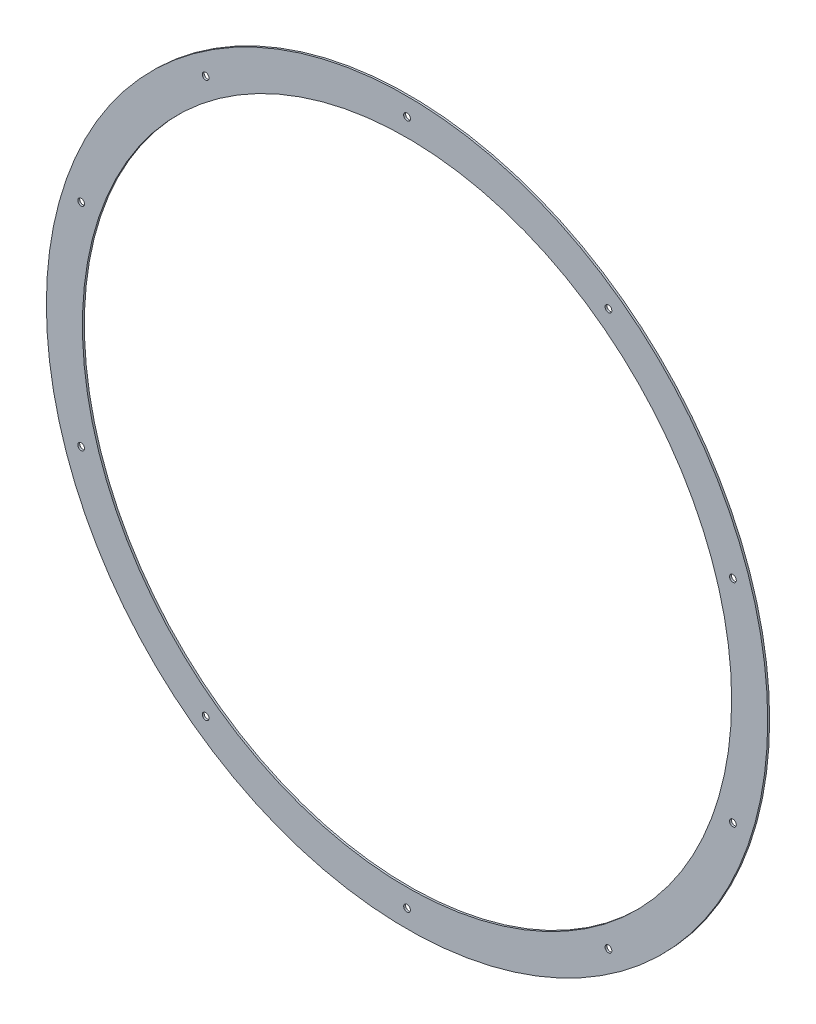
from build123d import *

# Parameters (mm, degrees)
SKETCH1_R          = 381
SKETCH1_R_2        = 342.9
EXTRUDE1_DEPTH     = 2.032
SKETCH2_R          = 3.556
CUT_EXTRUDE1_DEPTH = 2.032
CIRPATTERN1_COUNT  = 10


with BuildPart() as part:
    # Sketch1 → Extrude1 (new body)
    with BuildSketch(Plane.XY):
        Circle(SKETCH1_R)
        Circle(SKETCH1_R_2, mode=Mode.SUBTRACT)
    extrude(amount=EXTRUDE1_DEPTH)

    # Sketch2 → Cut-Extrude1 (cut)
    with BuildSketch(Plane.XY.offset(2.032)):
        with Locations((0, -361.95)):
            Circle(SKETCH2_R)
    cut_extrude1 = extrude(amount=-CUT_EXTRUDE1_DEPTH, mode=Mode.SUBTRACT)

    # CirPattern1: Cut-Extrude1 ×10 about axis
    cirpattern1_axis = Axis((0, 0, 0), (0, 0, 1))
    for i in range(1, CIRPATTERN1_COUNT):
        add(cut_extrude1.rotate(cirpattern1_axis, i * 360 / CIRPATTERN1_COUNT), mode=Mode.SUBTRACT)


solid = part.part
